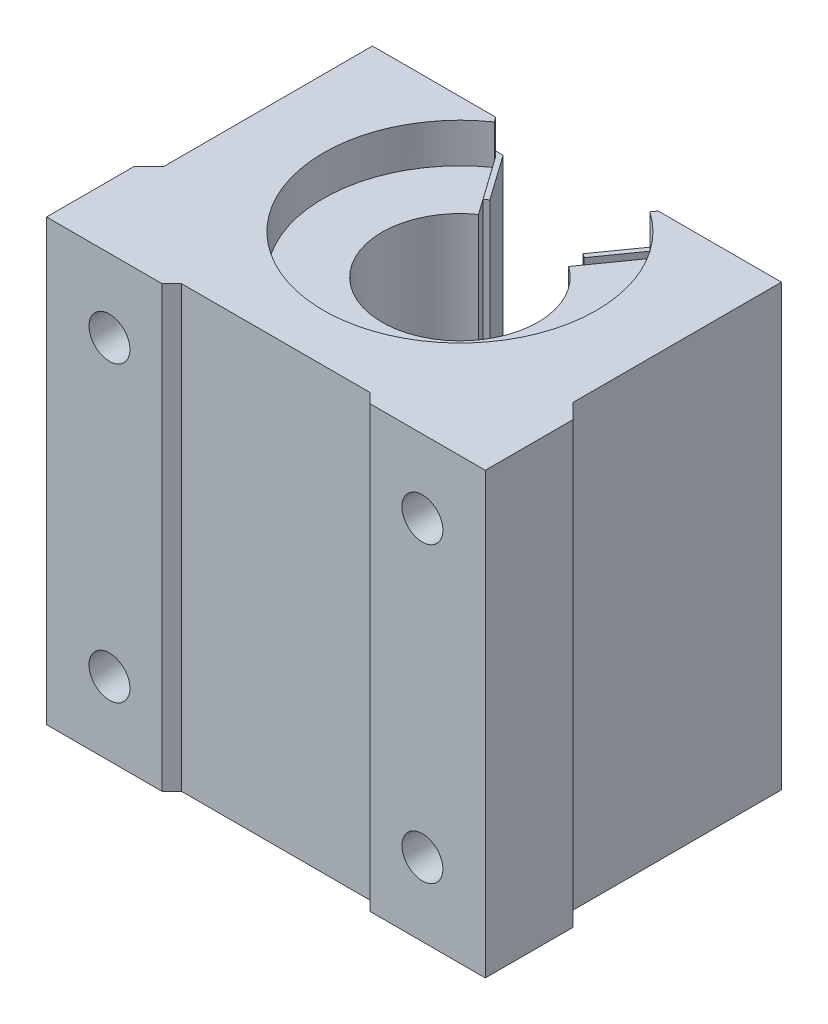
from build123d import *

# Parameters (mm, degrees)
MAIN_BODY_DEPTH             = 22.55
RUBBER_BEARING_SLEEVE_DEPTH = 18.5
BOSS_EXTRUDE3_DEPTH         = 19.05
M5X0_8_TAPPED_HOLE1_D       = 4.2
M5X0_8_TAPPED_HOLE1_DEPTH   = 16
M5X0_8_TAPPED_HOLE1_TIP     = 1.2618073


with BuildPart() as part:
    # Sketch1 → Main Body (new, symmetric)
    with BuildSketch(Plane(origin=(0, 0, 0), x_dir=(1, 0, 0), z_dir=(0, 1, 0))):
        with BuildLine():
            Line((-20.975, 12), (-20.975, -9.4))
            Line((-20.975, -9.4), (-22.5, -10.925))
            Line((-22.5, -10.925), (-22.5, -19.9))
            Line((-22.5, -19.9), (-10.675, -19.9))
            Line((-10.675, -19.9), (-9.675, -18.9))
            Line((-9.675, -18.9), (9.675, -18.9))
            Line((9.675, -18.9), (10.675, -19.9))
            Line((10.675, -19.9), (22.5, -19.9))
            Line((22.5, -19.9), (22.5, -10.925))
            Line((22.5, -10.925), (20.975, -9.4))
            Line((20.975, -9.4), (20.975, 12))
            Line((20.975, 12), (8.333560049, 12))
            Line((8.333560049, 12), (7.981030265, 11.502310894))
            ThreePointArc((7.981030265, 11.502310894), (0, -14), (-7.981030265, 11.502310894))
            Line((-7.981030265, 11.502310894), (-8.333560049, 12))
            Line((-8.333560049, 12), (-20.975, 12))
        make_face()
    extrude(amount=MAIN_BODY_DEPTH, both=True)

    # Sketch1_3 → Rubber Bearing Sleeve (add, symmetric)
    with BuildSketch(Plane(origin=(0, 0, 0), x_dir=(1, 0, 0), z_dir=(0, 1, 0))):
        with BuildLine():
            Line((-4.624138726, 6.528195849), (-8.092242771, 11.424342735))
            ThreePointArc((-8.092242771, 11.424342735), (-6.430730954, -12.435662403), (14, 0))
            ThreePointArc((14, 0), (12.435662403, 6.430730954), (8.092242771, 11.424342735))
            Line((8.092242771, 11.424342735), (4.624138726, 6.528195849))
            ThreePointArc((4.624138726, 6.528195849), (7.106092802, 3.674703402), (8, 0))
            ThreePointArc((8, 0), (-3.674703402, -7.106092802), (-4.624138726, 6.528195849))
        make_face()
    extrude(amount=RUBBER_BEARING_SLEEVE_DEPTH, both=True)

    # Sketch1_4 → Boss-Extrude3 (add, symmetric)
    with BuildSketch(Plane(origin=(0, 0, 0), x_dir=(1, 0, 0), z_dir=(0, 1, 0))):
        Polygon((-20.275, 12.5), (-20.275, 12), (-8.333560049, 12), (-5.188313398, 7.559651787), (-4.780301158, 7.848660458), (-8.075, 12.5), align=None)
        Polygon((8.333560049, 12), (20.275, 12), (20.275, 12.5), (8.075, 12.5), (4.780301158, 7.848660458), (5.188313398, 7.559651787), align=None)
    extrude(amount=BOSS_EXTRUDE3_DEPTH, both=True)

    # M5x0.8 Tapped Hole1
    with Locations(Plane.XY.offset(19.9)):
        with Locations((-16.05, 15.05), (16.05, 15.05), (16.05, -15.05), (-16.05, -15.05)):
            Hole(M5X0_8_TAPPED_HOLE1_D / 2, depth=M5X0_8_TAPPED_HOLE1_DEPTH)
            with Locations((0, 0, -(M5X0_8_TAPPED_HOLE1_DEPTH + M5X0_8_TAPPED_HOLE1_TIP / 2))):  # 118° drill point
                Cone(0, M5X0_8_TAPPED_HOLE1_D / 2, M5X0_8_TAPPED_HOLE1_TIP, mode=Mode.SUBTRACT)


solid = part.part
